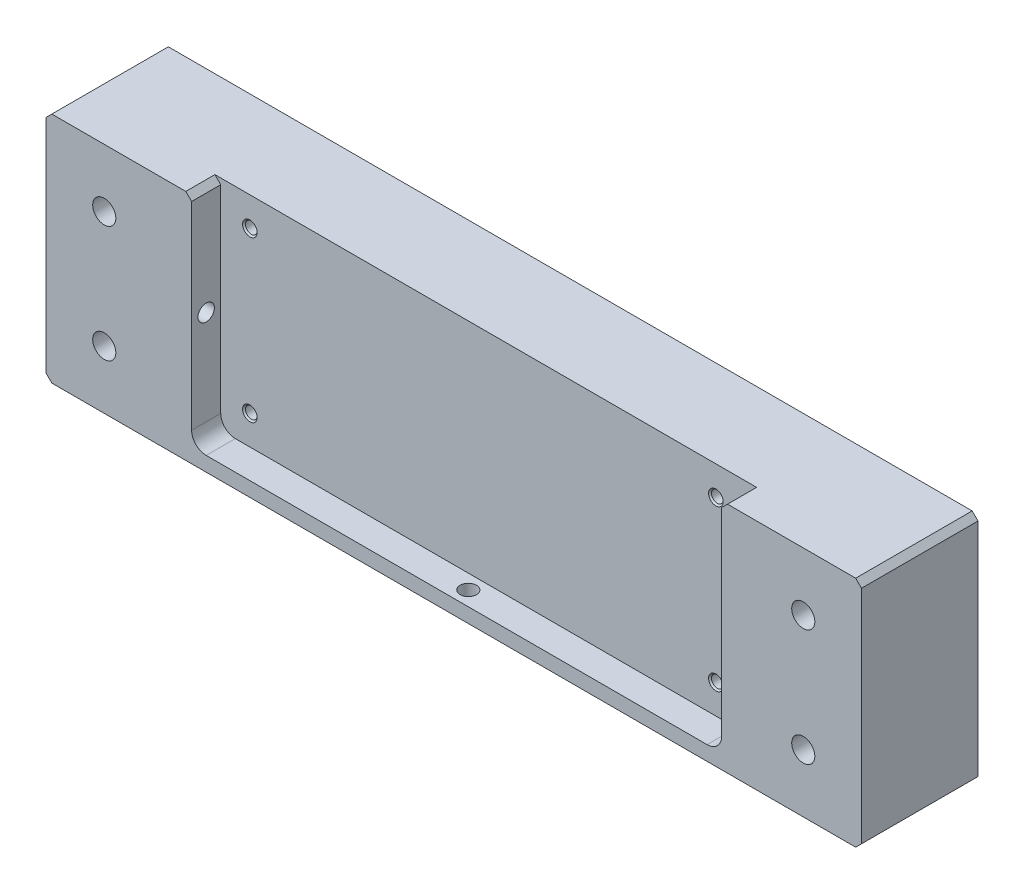
from build123d import *

# Parameters (mm, degrees)
SKETCH1_W                   = 355.6
SKETCH1_H                   = 101.6
EXTRUDE1_DEPTH              = 50.8
SKETCH6_W                   = 231.14
SKETCH6_H                   = 95.25
EXTRUDE2_DEPTH              = 12.7
FILLET1_R                   = 6.35
LPATTERN3_COUNT             = 2
LPATTERN3_PITCH             = 203.2
LPATTERN3_COUNT_DIR2        = 2
LPATTERN3_PITCH_DIR2        = 69.85
F_1_4_CLEARANCE_HOLE2_D     = 7.14248
F_1_4_CLEARANCE_HOLE2_DEPTH = 63.5
F_1_4_CLEARANCE_HOLE1_D     = 7.14248
LPATTERN4_COUNT             = 2
LPATTERN4_PITCH             = 50.8
LPATTERN4_COUNT_DIR2        = 2
LPATTERN4_PITCH_DIR2        = 304.8
CHAMFER1_SIZE               = 2.54


with BuildPart() as part:
    # Sketch1 → Extrude1 (new body)
    with BuildSketch(Plane.XY):
        Rectangle(SKETCH1_W, SKETCH1_H)
    extrude(amount=EXTRUDE1_DEPTH)

    # Sketch6 → Extrude2 (cut)
    with BuildSketch(Plane.XY.offset(50.8)):
        with Locations((1.27, 3.175)):
            Rectangle(SKETCH6_W, SKETCH6_H)
    extrude(amount=-EXTRUDE2_DEPTH, mode=Mode.SUBTRACT)

    # Fillet1
    fillet1_edges = [part.edges().sort_by_distance(p)[0] for p in [
        (116.84, -44.45, 44.45),
        (-114.3, -44.45, 44.45),
    ]]
    fillet(fillet1_edges, radius=FILLET1_R)

    # Sketch7 → 1/4-20 Tapped Hole1 (revolve, cut)
    with BuildSketch(Plane(origin=(101.6, -31.75, 38.1), x_dir=(0, -1, 0), z_dir=(1, 0, 0))):
        Polygon((0, 0), (0, 15.503816902), (2.5527, 13.97), (2.5527, 0.635), (3.1877, 0), align=None)
    f_1_4_20_tapped_hole1 = revolve(axis=Axis((101.6, -31.75, 44.45), (0, 0, -1)), mode=Mode.SUBTRACT)

    # LPattern3: 1_4-20 Tapped Hole1 2 × 2
    with Locations(*[(-i * LPATTERN3_PITCH, j * LPATTERN3_PITCH_DIR2, 0) for i in range(LPATTERN3_COUNT) for j in range(LPATTERN3_COUNT_DIR2) if (i, j) != (0, 0)]):
        add(f_1_4_20_tapped_hole1, mode=Mode.SUBTRACT)

    # 1/4 Clearance Hole2
    with Locations(Plane.ZY.offset(177.8)):
        with Locations((44.45, 3.175)):
            Hole(F_1_4_CLEARANCE_HOLE2_D / 2, depth=F_1_4_CLEARANCE_HOLE2_DEPTH)

    # 1/4 Clearance Hole1 (through all)
    with Locations(Plane.XZ.offset(50.8)):
        with Locations((0, 44.45)):
            Hole(F_1_4_CLEARANCE_HOLE1_D / 2)

    # Sketch14 → CBORE for 3/8 Socket Head Cap Screw1 (revolve, cut)
    with BuildSketch(Plane(origin=(152.4, 25.4, 0), x_dir=(0, 1, 0), z_dir=(1, 0, 0))):
        Polygon((0, 0), (0, 50.8), (5.0419, 50.8), (5.0419, 9.525), (7.9375, 9.525), (7.9375, 0.635), (8.5725, 0), align=None)
    cbore_for_3_8_socket_head_cap_screw1 = revolve(axis=Axis((152.4, 25.4, -6.35), (0, 0, 1)), mode=Mode.SUBTRACT)

    # LPattern4: CBORE for 3_8 Socket Head Cap Screw1 2 × 2
    with Locations(*[(-j * LPATTERN4_PITCH_DIR2, -i * LPATTERN4_PITCH, 0) for i in range(LPATTERN4_COUNT) for j in range(LPATTERN4_COUNT_DIR2) if (i, j) != (0, 0)]):
        add(cbore_for_3_8_socket_head_cap_screw1, mode=Mode.SUBTRACT)

    # Chamfer1
    chamfer1_edges = [part.edges().sort_by_distance(p)[0] for p in [
        (116.84, 50.8, 44.45),
        (-114.3, 50.8, 44.45),
        (177.8, -50.8, 25.4),
        (-177.8, -50.8, 25.4),
        (-177.8, 50.8, 25.4),
        (177.8, 50.8, 25.4),
    ]]
    chamfer(chamfer1_edges, length=CHAMFER1_SIZE)


solid = part.part
